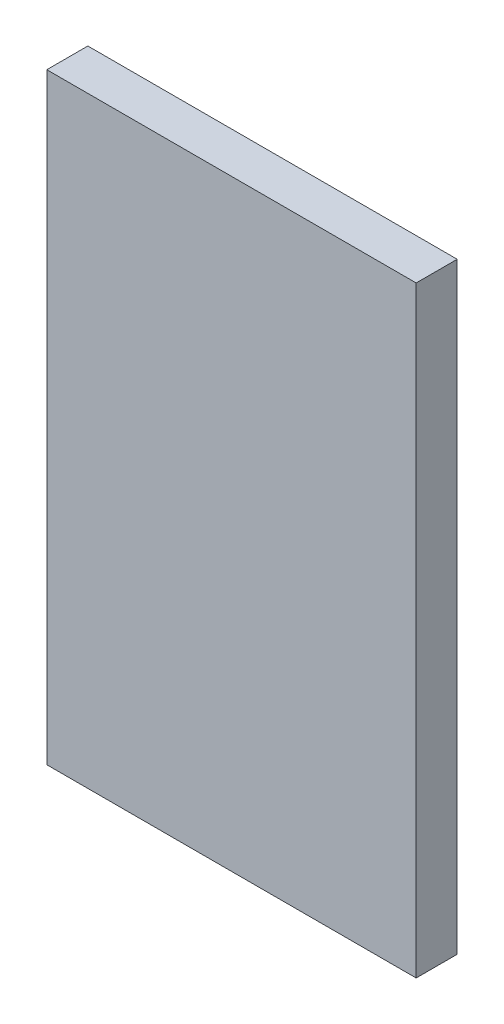
from build123d import *

# Parameters (mm, degrees)
ESQUISSE1_W      = 54
ESQUISSE1_H      = 88
EXTRUSION1_DEPTH = 6


with BuildPart() as part:
    # Esquisse1 → Extrusion1 (new body)
    with BuildSketch(Plane.XY):
        with Locations((27, 44)):
            Rectangle(ESQUISSE1_W, ESQUISSE1_H)
    extrude(amount=EXTRUSION1_DEPTH)


solid = part.part
